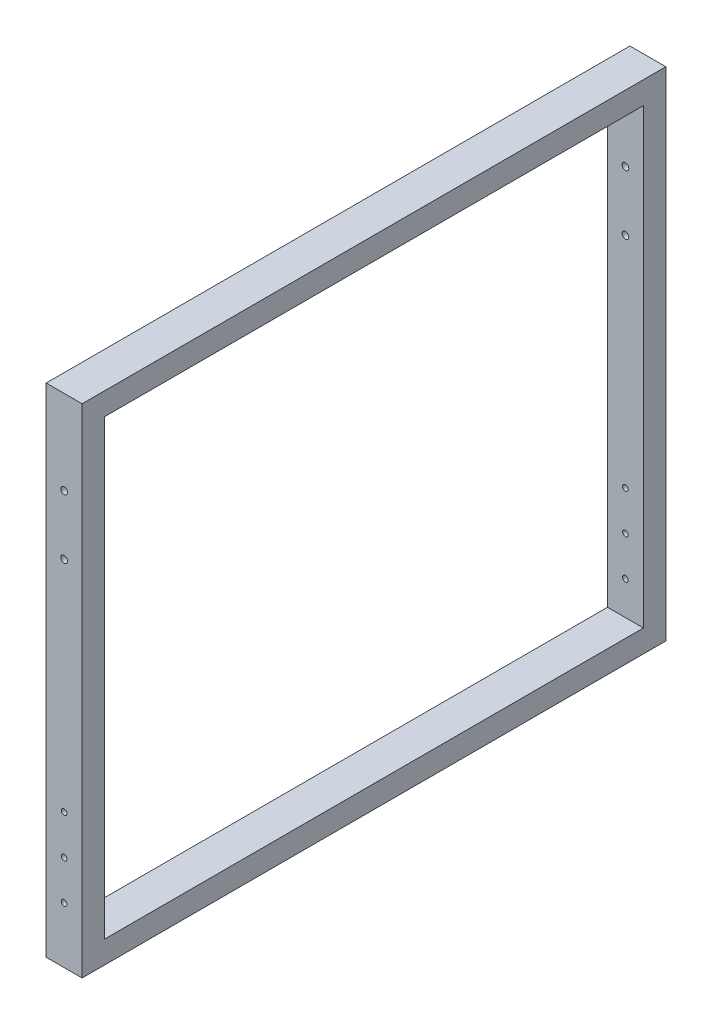
from build123d import *

# Parameters (mm, degrees)
SKETCH1_W               = 520
SKETCH1_H               = 443
SKETCH1_W_2             = 480
SKETCH1_H_2             = 403
BOSS_EXTRUDE2_DEPTH     = 32
SKETCH2_R               = 2.5
CUT_EXTRUDE1_DEPTH      = 610
SKETCH3_R               = 3
CUT_EXTRUDE2_DEPTH      = 641
CUT_EXTRUDE2_DEPTH_BACK = 105


with BuildPart() as part:
    # Sketch1 → Boss-Extrude2 (new body)
    with BuildSketch(Plane(origin=(0, 0, 0), x_dir=(0, 0, -1), z_dir=(1, 0, 0))):
        Rectangle(SKETCH1_W, SKETCH1_H)
        Rectangle(SKETCH1_W_2, SKETCH1_H_2, mode=Mode.SUBTRACT)
    extrude(amount=BOSS_EXTRUDE2_DEPTH)

    # Sketch2 → Cut-Extrude1 (cut)
    with BuildSketch(Plane.XY.offset(260)):
        with Locations((16, -171.5)):
            Circle(SKETCH2_R)
        with Locations((16, -136.5)):
            Circle(SKETCH2_R)
        with Locations((16, -101.5)):
            Circle(SKETCH2_R)
    extrude(amount=-CUT_EXTRUDE1_DEPTH, mode=Mode.SUBTRACT)

    # Sketch3 → Cut-Extrude2 (cut, two sides)
    with BuildSketch(Plane(origin=(0, 0, 240), x_dir=(-1, 0, 0), z_dir=(0, 0, -1))) as cut_extrude2_sk:
        with Locations((-16, 146.5)):
            Circle(SKETCH3_R)
        with Locations((-16, 93.5)):
            Circle(SKETCH3_R)
    extrude(amount=CUT_EXTRUDE2_DEPTH, mode=Mode.SUBTRACT)
    extrude(cut_extrude2_sk.sketch, amount=-CUT_EXTRUDE2_DEPTH_BACK, mode=Mode.SUBTRACT)


solid = part.part
